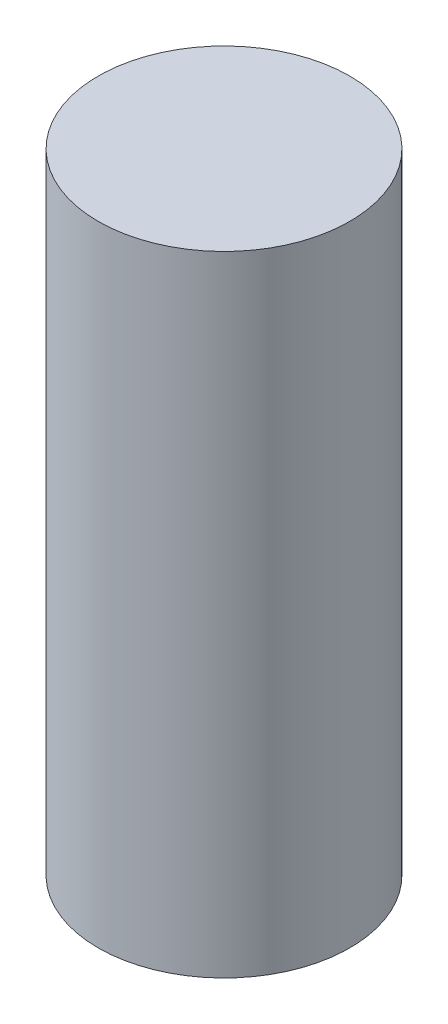
from build123d import *

# Parameters (mm, degrees)
SKETCH1_R           = 2.5
BOSS_EXTRUDE1_DEPTH = 12.5


with BuildPart() as part:
    # Sketch1 → Boss-Extrude1 (new body)
    with BuildSketch(Plane(origin=(0, 0, 0), x_dir=(1, 0, 0), z_dir=(0, 1, 0))):
        Circle(SKETCH1_R)
    extrude(amount=BOSS_EXTRUDE1_DEPTH)


solid = part.part
